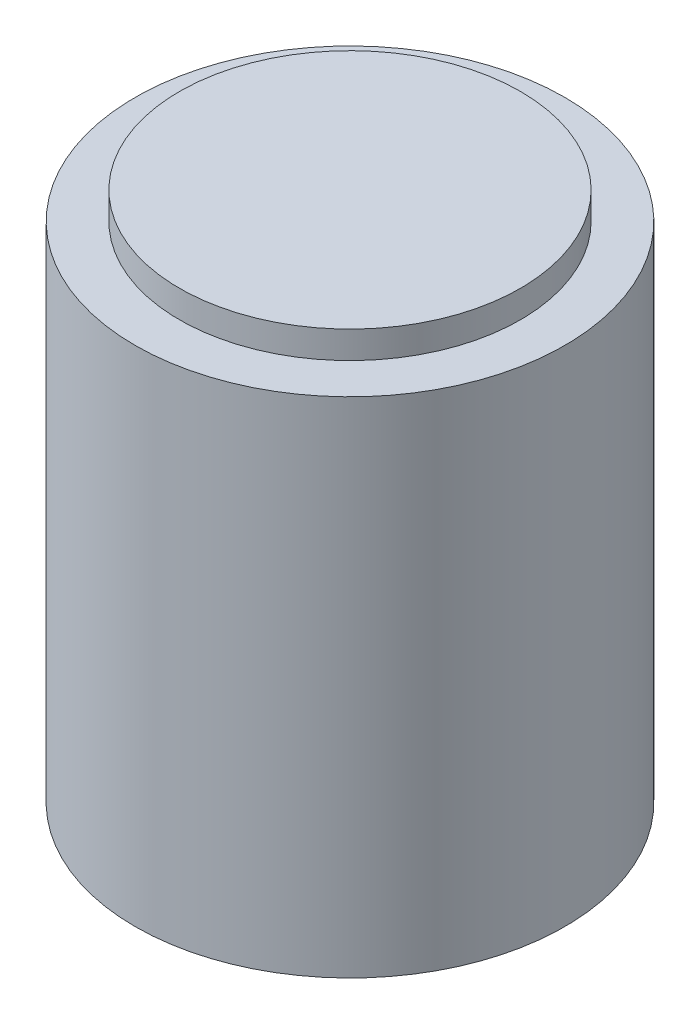
from build123d import *


with BuildPart() as part:
    # Sketch1 → Revolve1 (revolve)
    with BuildSketch(Plane.XY):
        Polygon((0, 38.9), (12.5, 38.9), (12.5, 36.9), (15.75, 36.9), (15.75, 0), (0, 0), align=None)
    revolve(axis=Axis((0, 0, 0), (0, 1, 0)))


solid = part.part
